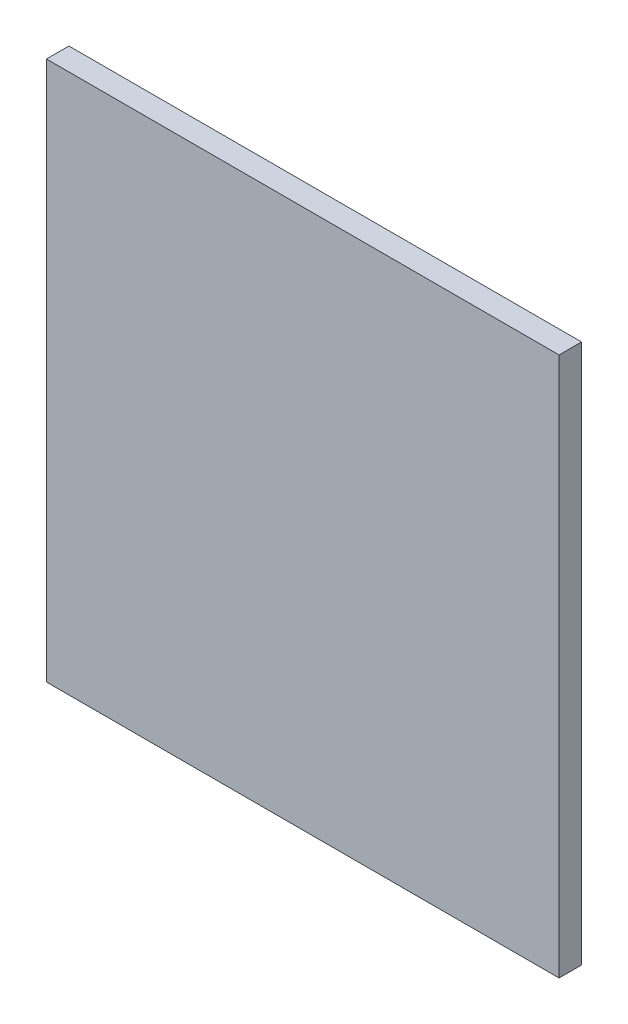
from build123d import *

# Parameters (mm, degrees)
SKETCH1_W           = 72.39
SKETCH1_H           = 76.2
BOSS_EXTRUDE1_DEPTH = 3.175


with BuildPart() as part:
    # Sketch1 → Boss-Extrude1 (new body)
    with BuildSketch(Plane.XY):
        with Locations((36.195, 38.1)):
            Rectangle(SKETCH1_W, SKETCH1_H)
    extrude(amount=BOSS_EXTRUDE1_DEPTH)


solid = part.part
